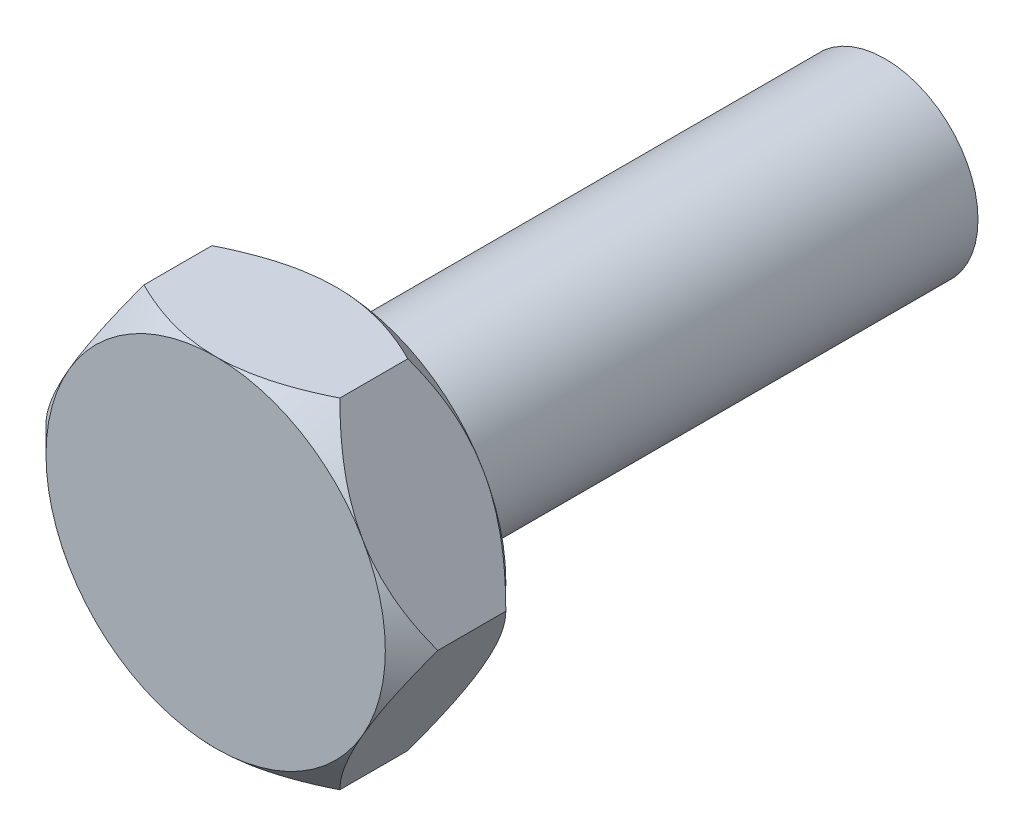
from build123d import *

# Parameters (mm, degrees)
BOSS_EXTRUDE1_DEPTH = 3.895
SKETCH2_OUTSIDE_W   = 51.796
SKETCH2_OUTSIDE_H   = 48.402
SKETCH2_OUTSIDE_R   = 10.969655115
CUT_EXTRUDE1_DEPTH  = 8.79
CUT_EXTRUDE1_TAPER  = 45
SKETCH3_R           = 6
BOSS_EXTRUDE2_DEPTH = 35.5


with BuildPart() as part:
    # Sketch1 → Boss-Extrude1 (new body, symmetric)
    with BuildSketch(Plane.XY):
        Polygon((-6.333333333, 10.969655115), (-12.666666667, 0), (-6.333333333, -10.969655115), (6.333333333, -10.969655115), (12.666666667, 0), (6.333333333, 10.969655115), align=None)
    extrude(amount=BOSS_EXTRUDE1_DEPTH, both=True)

    # Sketch2 outside → Cut-Extrude1 (cut, through all)
    with BuildSketch(Plane.XY.offset(3.895)):
        Rectangle(SKETCH2_OUTSIDE_W, SKETCH2_OUTSIDE_H)
        Circle(SKETCH2_OUTSIDE_R, mode=Mode.SUBTRACT)
    cut_extrude1 = extrude(amount=-CUT_EXTRUDE1_DEPTH, taper=CUT_EXTRUDE1_TAPER, mode=Mode.SUBTRACT)

    # Mirror1: Cut-Extrude1 across plane
    add(cut_extrude1.mirror(Plane.XY), mode=Mode.SUBTRACT)

    # Sketch3 → Boss-Extrude2 (add)
    with BuildSketch(Plane(origin=(0, 0, -3.895), x_dir=(-1, 0, 0), z_dir=(0, 0, -1))):
        Circle(SKETCH3_R)
    extrude(amount=BOSS_EXTRUDE2_DEPTH)


solid = part.part
